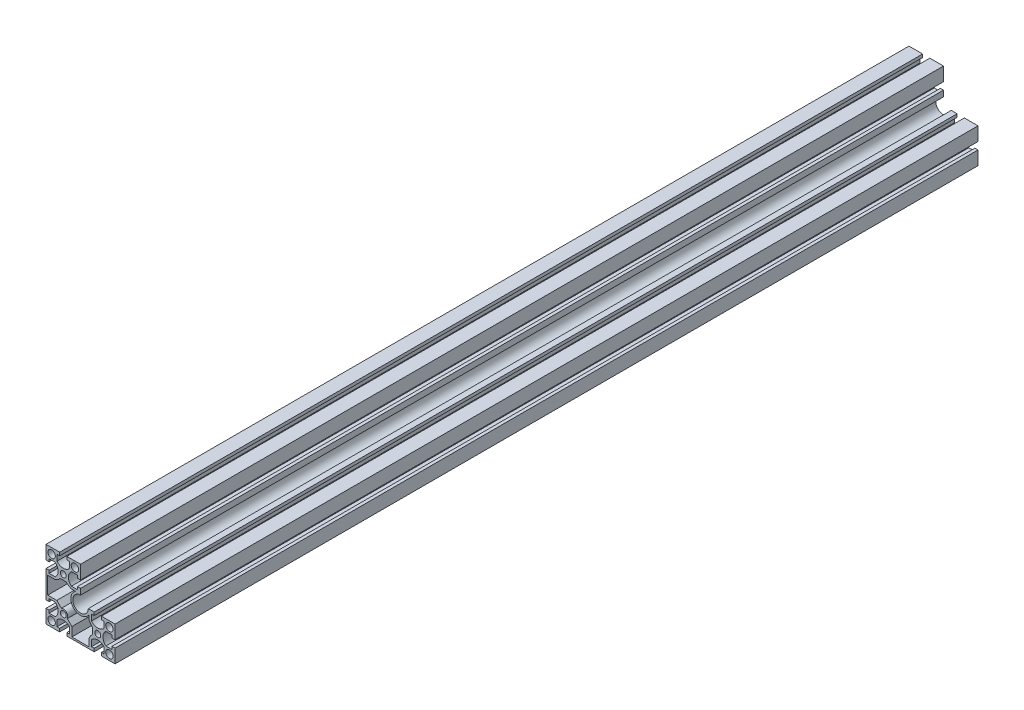
from build123d import *

# Parameters (mm, degrees)
SKETCH_1_R      = 3.4
SKETCH_1_R_2    = 4.3
EXTRUDE_1_DEPTH = 1000


with BuildPart() as part:
    # Эскиз1 → Бобышка-Вытянуть1 (new body)
    with BuildSketch(Plane.XY):
        with BuildLine():
            Line((-20, 47.3), (-20, 60))
            Line((-20, 60), (-7.3, 60))
            Line((-7.3, 60), (-4.2, 60))
            Line((-4.2, 60), (-4.2, 56.4))
            Line((-4.2, 56.4), (-7.3, 56.4))
            Line((-7.3, 56.4), (-7.3, 49.4))
            ThreePointArc((-7.3, 49.4), (0, 45.979473661), (7.3, 49.4))
            Line((7.3, 49.4), (7.3, 56.4))
            Line((7.3, 56.4), (4.2, 56.4))
            Line((4.2, 56.4), (4.2, 60))
            Line((4.2, 60), (7.3, 60))
            Line((7.3, 60), (20, 60))
            Line((20, 60), (20, 47.3))
            Line((20, 47.3), (20, 44.2))
            Line((20, 44.2), (16.4, 44.2))
            Line((16.4, 44.2), (16.4, 47.3))
            Line((16.4, 47.3), (9.4, 47.3))
            ThreePointArc((9.4, 47.3), (5.979473661, 40), (9.4, 32.7))
            Line((9.4, 32.7), (16.4, 32.7))
            Line((16.4, 32.7), (16.4, 35.8))
            Line((16.4, 35.8), (20, 35.8))
            Line((20, 35.8), (20, 32.7))
            Line((20, 32.7), (20, 29))
            ThreePointArc((20, 29), (13.636038969, 13.636038969), (29, 20))
            Line((29, 20), (32.7, 20))
            Line((32.7, 20), (35.8, 20))
            Line((35.8, 20), (35.8, 16.4))
            Line((35.8, 16.4), (32.7, 16.4))
            Line((32.7, 16.4), (32.7, 9.4))
            ThreePointArc((32.7, 9.4), (40, 5.979473661), (47.3, 9.4))
            Line((47.3, 9.4), (47.3, 16.4))
            Line((47.3, 16.4), (44.2, 16.4))
            Line((44.2, 16.4), (44.2, 20))
            Line((44.2, 20), (47.3, 20))
            Line((47.3, 20), (60, 20))
            Line((60, 20), (60, 7.3))
            Line((60, 7.3), (60, 4.2))
            Line((60, 4.2), (56.4, 4.2))
            Line((56.4, 4.2), (56.4, 7.3))
            Line((56.4, 7.3), (49.4, 7.3))
            ThreePointArc((49.4, 7.3), (45.979473661, 0), (49.4, -7.3))
            Line((49.4, -7.3), (56.4, -7.3))
            Line((56.4, -7.3), (56.4, -4.2))
            Line((56.4, -4.2), (60, -4.2))
            Line((60, -4.2), (60, -7.3))
            Line((60, -7.3), (60, -20))
            Line((60, -20), (47.3, -20))
            Line((47.3, -20), (44.2, -20))
            Line((44.2, -20), (44.2, -16.4))
            Line((44.2, -16.4), (47.3, -16.4))
            Line((47.3, -16.4), (47.3, -9.4))
            ThreePointArc((47.3, -9.4), (40, -5.979473661), (32.7, -9.4))
            Line((32.7, -9.4), (32.7, -16.4))
            Line((32.7, -16.4), (35.8, -16.4))
            Line((35.8, -16.4), (35.8, -20))
            Line((35.8, -20), (32.7, -20))
            Line((32.7, -20), (7.3, -20))
            Line((7.3, -20), (4.2, -20))
            Line((4.2, -20), (4.2, -16.4))
            Line((4.2, -16.4), (7.3, -16.4))
            Line((7.3, -16.4), (7.3, -9.4))
            ThreePointArc((7.3, -9.4), (0, -5.979473661), (-7.3, -9.4))
            Line((-7.3, -9.4), (-7.3, -16.4))
            Line((-7.3, -16.4), (-4.2, -16.4))
            Line((-4.2, -16.4), (-4.2, -20))
            Line((-4.2, -20), (-7.3, -20))
            Line((-7.3, -20), (-20, -20))
            Line((-20, -20), (-20, -7.3))
            Line((-20, -7.3), (-20, -4.2))
            Line((-20, -4.2), (-16.4, -4.2))
            Line((-16.4, -4.2), (-16.4, -7.3))
            Line((-16.4, -7.3), (-9.4, -7.3))
            ThreePointArc((-9.4, -7.3), (-5.979473661, 0), (-9.4, 7.3))
            Line((-9.4, 7.3), (-16.4, 7.3))
            Line((-16.4, 7.3), (-16.4, 4.2))
            Line((-16.4, 4.2), (-20, 4.2))
            Line((-20, 4.2), (-20, 7.3))
            Line((-20, 7.3), (-20, 32.7))
            Line((-20, 32.7), (-20, 35.8))
            Line((-20, 35.8), (-16.4, 35.8))
            Line((-16.4, 35.8), (-16.4, 32.7))
            Line((-16.4, 32.7), (-9.4, 32.7))
            ThreePointArc((-9.4, 32.7), (-5.979473661, 40), (-9.4, 47.3))
            Line((-9.4, 47.3), (-16.4, 47.3))
            Line((-16.4, 47.3), (-16.4, 44.2))
            Line((-16.4, 44.2), (-20, 44.2))
            Line((-20, 44.2), (-20, 47.3))
        make_face()
        with Locations((0, 40)):
            Circle(SKETCH_1_R, mode=Mode.SUBTRACT)
        with Locations((-13.5, 53.5)):
            Circle(SKETCH_1_R_2, mode=Mode.SUBTRACT)
        with Locations((13.5, 53.5)):
            Circle(SKETCH_1_R_2, mode=Mode.SUBTRACT)
        with Locations((-13.5, -13.5)):
            Circle(SKETCH_1_R_2, mode=Mode.SUBTRACT)
        Circle(SKETCH_1_R, mode=Mode.SUBTRACT)
        with Locations((40, 0)):
            Circle(SKETCH_1_R, mode=Mode.SUBTRACT)
        with Locations((53.5, 13.5)):
            Circle(SKETCH_1_R_2, mode=Mode.SUBTRACT)
        with Locations((53.5, -13.5)):
            Circle(SKETCH_1_R_2, mode=Mode.SUBTRACT)
        with BuildLine():
            Line((-2.207961827, 4.707961827), (-7.5, 10))
            Line((-7.5, 10), (-18, 10))
            Line((-18, 10), (-18, 30))
            Line((-18, 30), (-9, 30))
            Line((-9, 30), (-5.450961894, 32.049038106))
            Line((-5.450961894, 32.049038106), (-3.5, 34))
            Line((-3.5, 34), (3.5, 34))
            Line((3.5, 34), (5.450961894, 32.049038106))
            Line((5.450961894, 32.049038106), (9, 30))
            Line((9, 30), (14.737871153, 30))
            ThreePointArc((14.737871153, 30), (12.009693373, 12.009693373), (30, 14.737871153))
            Line((30, 14.737871153), (30, 9))
            Line((30, 9), (32.049038106, 5.450961894))
            Line((32.049038106, 5.450961894), (34, 3.5))
            Line((34, 3.5), (34, -3.5))
            Line((34, -3.5), (32.049038106, -5.450961894))
            Line((32.049038106, -5.450961894), (30, -9))
            Line((30, -9), (30, -18))
            Line((30, -18), (10, -18))
            Line((10, -18), (10, -7.5))
            Line((10, -7.5), (4.707961827, -2.207961827))
            ThreePointArc((4.707961827, -2.207961827), (3.676955262, 3.676955262), (-2.207961827, 4.707961827))
        make_face(mode=Mode.SUBTRACT)
    extrude(amount=EXTRUDE_1_DEPTH)


solid = part.part
